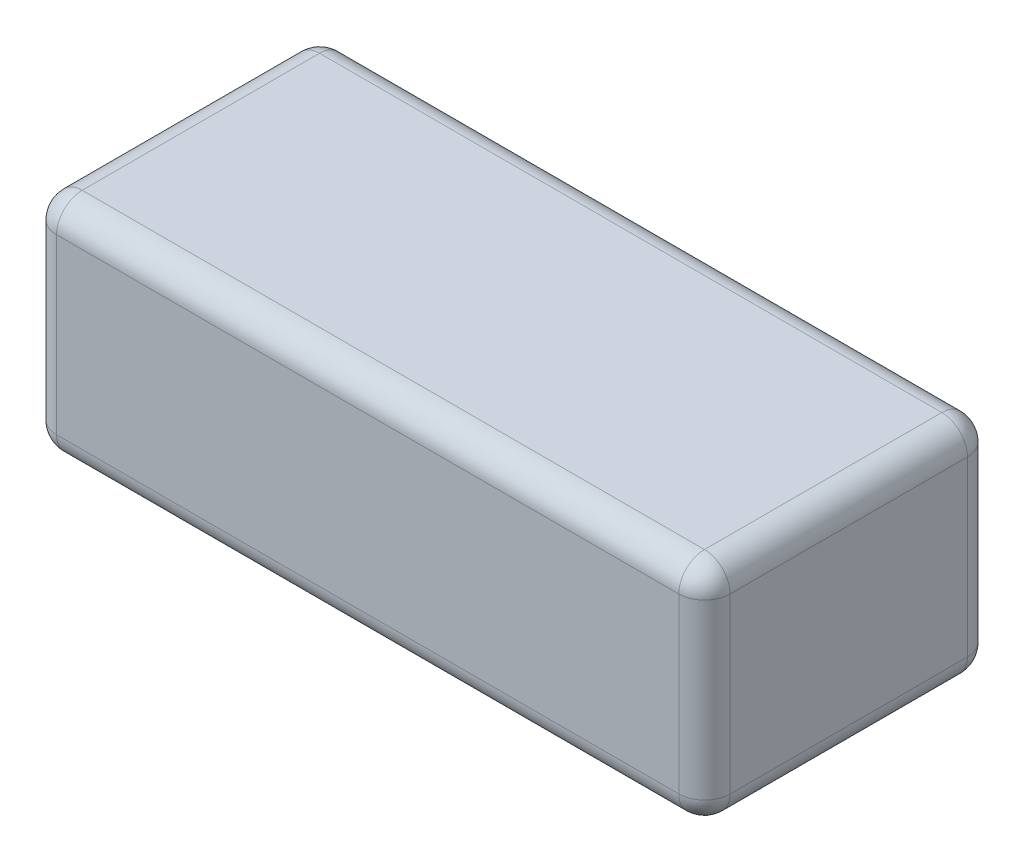
from build123d import *

# Parameters (mm, degrees)
SKETCH1_W           = 105
SKETCH1_H           = 45
BOSS_EXTRUDE1_DEPTH = 35
FILLET1_R           = 4


with BuildPart() as part:
    # Sketch1 → Boss-Extrude1 (new body)
    with BuildSketch(Plane(origin=(0, 0, 0), x_dir=(1, 0, 0), z_dir=(0, 1, 0))):
        Rectangle(SKETCH1_W, SKETCH1_H)
    extrude(amount=BOSS_EXTRUDE1_DEPTH)

    # Fillet1
    fillet1_edges = [part.edges().sort_by_distance(p)[0] for p in [
        (-52.5, 35, 0),
        (0, 35, 22.5),
        (52.5, 35, 0),
        (0, 0, 22.5),
        (-52.5, 0, 0),
        (0, 0, -22.5),
        (52.5, 0, 0),
        (0, 35, -22.5),
        (52.5, 17.5, 22.5),
        (-52.5, 17.5, 22.5),
        (-52.5, 17.5, -22.5),
        (52.5, 17.5, -22.5),
    ]]
    fillet(fillet1_edges, radius=FILLET1_R)


solid = part.part
